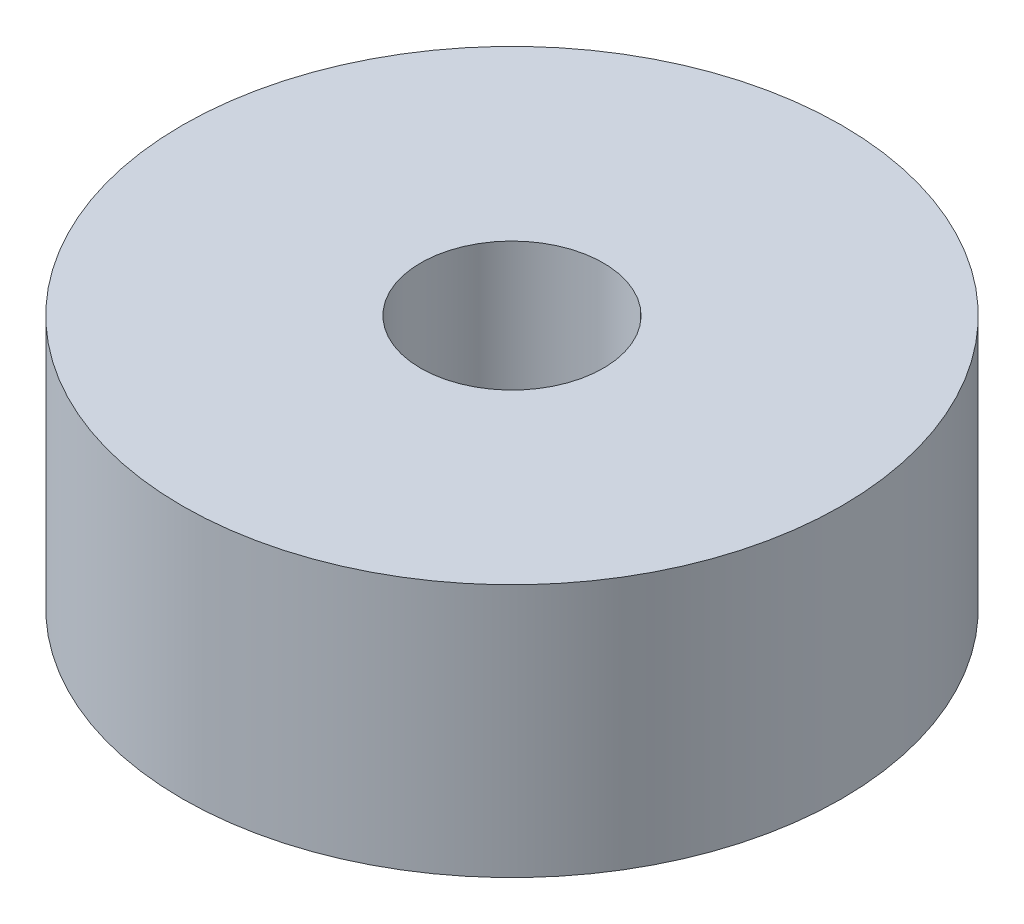
from build123d import *

# Parameters (mm, degrees)
SKETCH_1_R      = 6.5
SKETCH_1_R_2    = 1.8
EXTRUDE_1_DEPTH = 5


with BuildPart() as part:
    # Эскиз1 → Бобышка-Вытянуть1 (new body)
    with BuildSketch(Plane(origin=(0, 0, 0), x_dir=(1, 0, 0), z_dir=(0, 1, 0))):
        Circle(SKETCH_1_R)
        Circle(SKETCH_1_R_2, mode=Mode.SUBTRACT)
    extrude(amount=EXTRUDE_1_DEPTH)


solid = part.part
